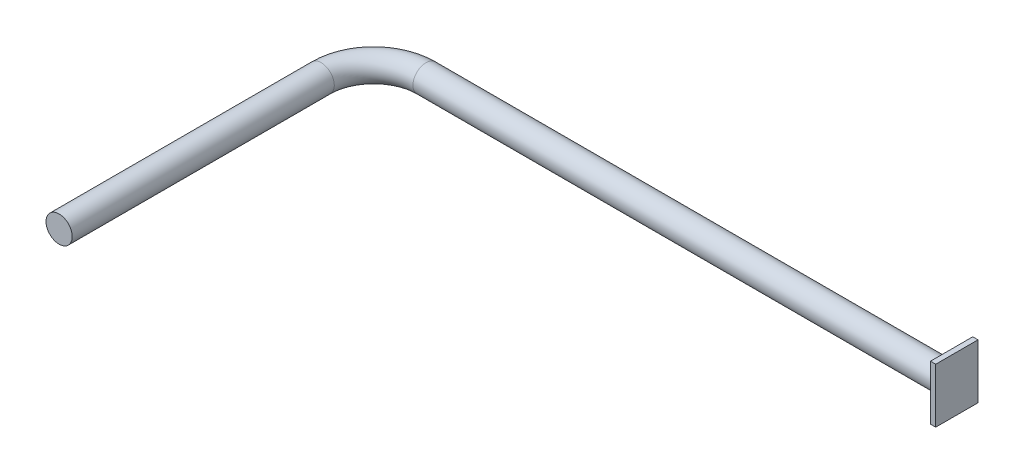
from build123d import *

# Parameters (mm, degrees)
SKETCH1_R           = 25
SKETCH4_W           = 80.61138344
SKETCH4_H           = 104.08052039
BOSS_EXTRUDE1_DEPTH = 10


with BuildPart() as part:
    # Sweep1: sweep along a path in Sketch3
    with BuildLine(Plane(origin=(0, 0, 0), x_dir=(1, 0, 0), z_dir=(0, 1, 0))) as sweep1_path:
        Line((0, 0), (0, 500))
        ThreePointArc((0, 500), (29.289321881, 570.710678119), (100, 600))
        Line((100, 600), (1100, 600))
    # Sketch1 → Sweep1 (sweep)
    with BuildSketch(Plane.XY):
        Circle(SKETCH1_R)
    sweep(path=sweep1_path.line)

    # Sketch4 → Boss-Extrude1 (add)
    with BuildSketch(Plane(origin=(1100, 0, 0), x_dir=(0, 0, -1), z_dir=(1, 0, 0))):
        with Locations((602.803020109, -1.530595888)):
            Rectangle(SKETCH4_W, SKETCH4_H)
    extrude(amount=BOSS_EXTRUDE1_DEPTH)


solid = part.part
